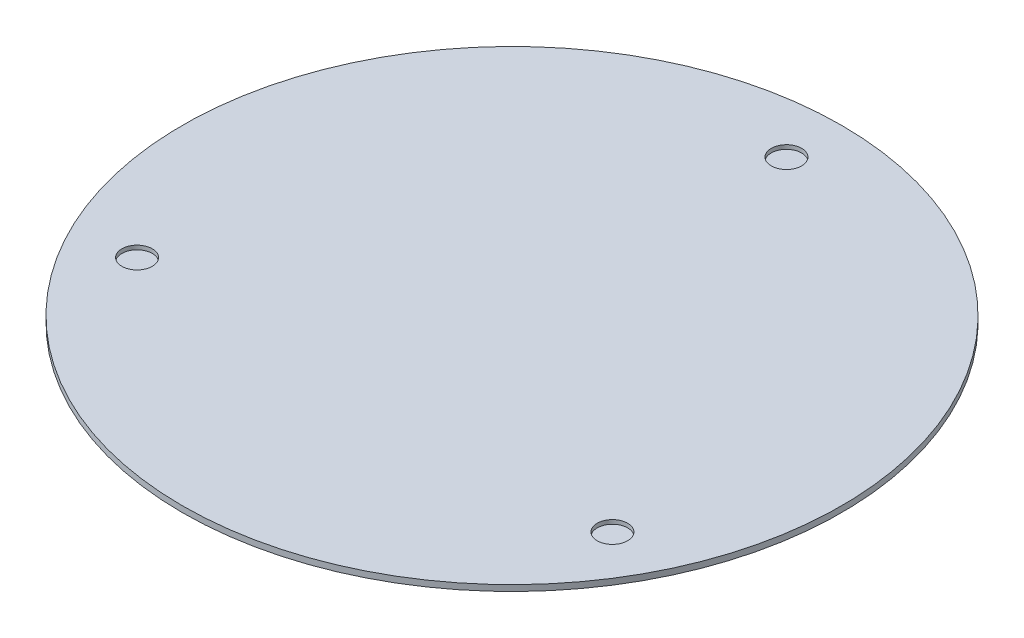
from build123d import *

# Parameters (mm, degrees)
SKETCH1_R           = 165.1
BOSS_EXTRUDE1_DEPTH = 3
SKETCH2_R           = 7.62
CUT_EXTRUDE1_DEPTH  = 2.032


with BuildPart() as part:
    # Sketch1 → Boss-Extrude1 (new body)
    with BuildSketch(Plane(origin=(0, 0, 0), x_dir=(1, 0, 0), z_dir=(0, 1, 0))):
        Circle(SKETCH1_R)
    extrude(amount=BOSS_EXTRUDE1_DEPTH)

    # Sketch2 → Cut-Extrude1 (cut)
    with BuildSketch(Plane(origin=(0, 3, 0), x_dir=(1, 0, 0), z_dir=(0, 1, 0))):
        with Locations((0, 137.4902)):
            Circle(SKETCH2_R)
        with Locations((119.070005971, -68.7451)):
            Circle(SKETCH2_R)
        with Locations((-119.070005971, -68.7451)):
            Circle(SKETCH2_R)
    extrude(amount=-CUT_EXTRUDE1_DEPTH, mode=Mode.SUBTRACT)


solid = part.part
